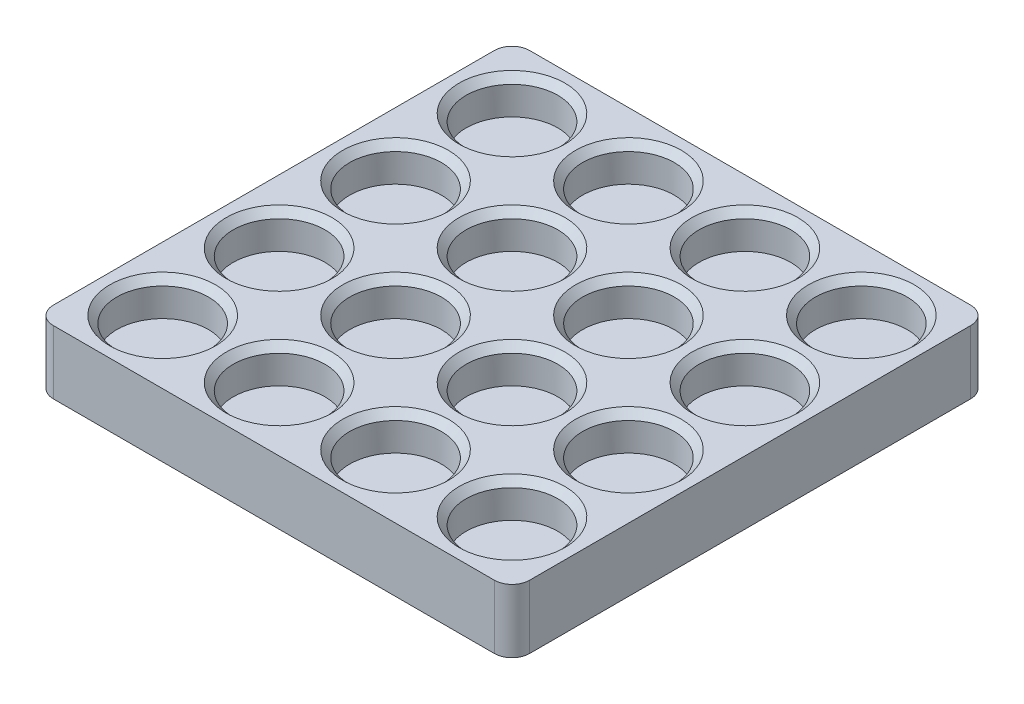
from build123d import *

# Parameters (mm, degrees)
SKETCH1_W           = 135
SKETCH1_H           = 135
BOSS_EXTRUDE1_DEPTH = 18
FILLET1_R           = 5
SKETCH2_R           = 13
CUT_EXTRUDE1_DEPTH  = 10
CHAMFER1_SIZE       = 2


with BuildPart() as part:
    # Sketch1 → Boss-Extrude1 (new body)
    with BuildSketch(Plane(origin=(0, 0, 0), x_dir=(1, 0, 0), z_dir=(0, 1, 0))):
        Rectangle(SKETCH1_W, SKETCH1_H)
    extrude(amount=BOSS_EXTRUDE1_DEPTH)

    # Fillet1
    fillet1_edges = [part.edges().sort_by_distance(p)[0] for p in [
        (67.5, 9, 67.5),
        (-67.5, 9, 67.5),
        (-67.5, 9, -67.5),
        (67.5, 9, -67.5),
    ]]
    fillet(fillet1_edges, radius=FILLET1_R)

    # Sketch2 → Cut-Extrude1 (cut)
    with BuildSketch(Plane(origin=(0, 18, 0), x_dir=(1, 0, 0), z_dir=(0, 1, 0))):
        with Locations((-49.5, 49.5)):
            Circle(SKETCH2_R)
        with Locations((49.5, 49.5)):
            Circle(SKETCH2_R)
        with Locations((49.5, -49.5)):
            Circle(SKETCH2_R)
        with Locations((-49.5, -49.5)):
            Circle(SKETCH2_R)
        with Locations((-16.5, 49.5)):
            Circle(SKETCH2_R)
        with Locations((16.5, 49.5)):
            Circle(SKETCH2_R)
        with Locations((-16.5, 16.5)):
            Circle(SKETCH2_R)
        with Locations((-49.5, 16.5)):
            Circle(SKETCH2_R)
        with Locations((-16.5, -49.5)):
            Circle(SKETCH2_R)
        with Locations((-49.5, -16.5)):
            Circle(SKETCH2_R)
        with Locations((-16.5, -16.5)):
            Circle(SKETCH2_R)
        with Locations((49.5, 16.5)):
            Circle(SKETCH2_R)
        with Locations((16.5, 16.5)):
            Circle(SKETCH2_R)
        with Locations((49.5, -16.5)):
            Circle(SKETCH2_R)
        with Locations((16.5, -16.5)):
            Circle(SKETCH2_R)
        with Locations((16.5, -49.5)):
            Circle(SKETCH2_R)
    extrude(amount=-CUT_EXTRUDE1_DEPTH, mode=Mode.SUBTRACT)

    # Chamfer1
    chamfer1_edges = [part.edges().sort_by_distance(p)[0] for p in [
        (3.5, 18, -49.5),
        (-29.5, 18, -16.5),
        (-62.5, 18, -16.5),
        (-29.5, 18, 49.5),
        (-29.5, 18, -49.5),
        (-62.5, 18, 49.5),
        (36.5, 18, 49.5),
        (36.5, 18, -49.5),
        (3.5, 18, 49.5),
        (3.5, 18, 16.5),
        (36.5, 18, 16.5),
        (3.5, 18, -16.5),
        (36.5, 18, -16.5),
        (-29.5, 18, 16.5),
        (-62.5, 18, 16.5),
        (-62.5, 18, -49.5),
    ]]
    chamfer(chamfer1_edges, length=CHAMFER1_SIZE)


solid = part.part
